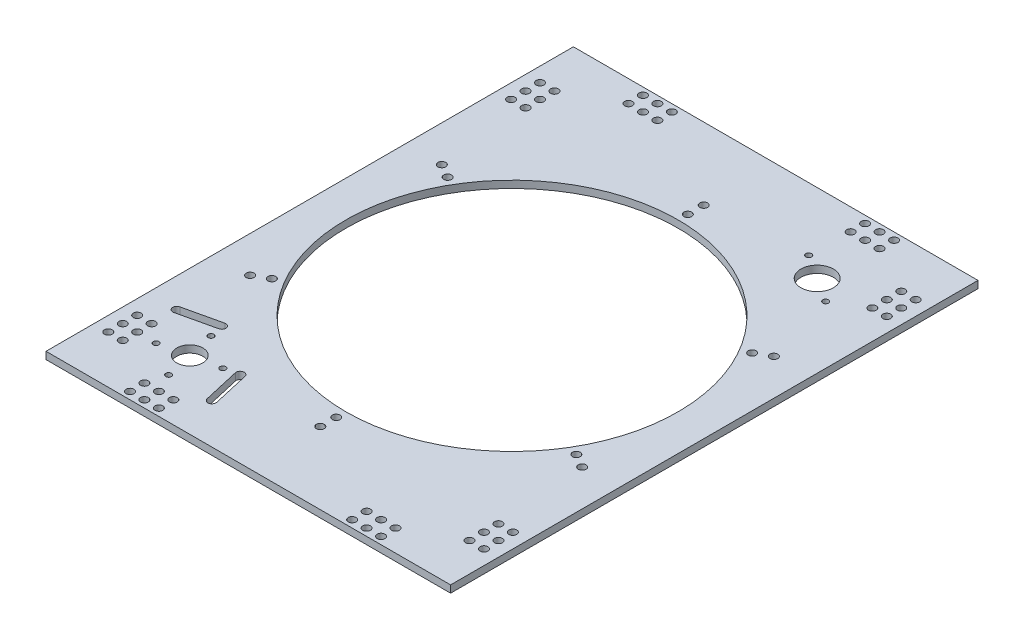
from build123d import *

# Parameters (mm, degrees)
SKETCH1_W           = 355.6
SKETCH1_H           = 463.55
SKETCH1_R           = 146.05
SKETCH1_R_2         = 3.429
SKETCH1_R_3         = 2.54
SKETCH1_R_4         = 11.43
SKETCH1_R_5         = 14.2875
BOSS_EXTRUDE1_DEPTH = 6.35


with BuildPart() as part:
    # Sketch1 → Boss-Extrude1 (new body)
    with BuildSketch(Plane(origin=(0, 0, 0), x_dir=(1, 0, 0), z_dir=(0, 1, 0))):
        Rectangle(SKETCH1_W, SKETCH1_H)
        Circle(SKETCH1_R, mode=Mode.SUBTRACT)
        with Locations((0, 168.5)):
            Circle(SKETCH1_R_2, mode=Mode.SUBTRACT)
        with Locations((145.925280538, 84.25)):
            Circle(SKETCH1_R_2, mode=Mode.SUBTRACT)
        with Locations((145.925280538, -84.25)):
            Circle(SKETCH1_R_2, mode=Mode.SUBTRACT)
        with Locations((0, -168.5)):
            Circle(SKETCH1_R_2, mode=Mode.SUBTRACT)
        with Locations((-145.925280538, -84.25)):
            Circle(SKETCH1_R_2, mode=Mode.SUBTRACT)
        with Locations((-145.925280538, 84.25)):
            Circle(SKETCH1_R_2, mode=Mode.SUBTRACT)
        with Locations((-165.1, 189.7126)):
            Circle(SKETCH1_R_2, mode=Mode.SUBTRACT)
        with Locations((-152.4, 189.7126)):
            Circle(SKETCH1_R_2, mode=Mode.SUBTRACT)
        with Locations((-152.4, 177.0126)):
            Circle(SKETCH1_R_2, mode=Mode.SUBTRACT)
        with Locations((-165.1, 177.0126)):
            Circle(SKETCH1_R_2, mode=Mode.SUBTRACT)
        with Locations((-152.4, 164.3126)):
            Circle(SKETCH1_R_2, mode=Mode.SUBTRACT)
        with Locations((-165.1, 164.3126)):
            Circle(SKETCH1_R_2, mode=Mode.SUBTRACT)
        with Locations((165.1, 164.3126)):
            Circle(SKETCH1_R_2, mode=Mode.SUBTRACT)
        with Locations((152.4, 164.3126)):
            Circle(SKETCH1_R_2, mode=Mode.SUBTRACT)
        with Locations((165.1, 177.0126)):
            Circle(SKETCH1_R_2, mode=Mode.SUBTRACT)
        with Locations((152.4, 177.0126)):
            Circle(SKETCH1_R_2, mode=Mode.SUBTRACT)
        with Locations((152.4, 189.7126)):
            Circle(SKETCH1_R_2, mode=Mode.SUBTRACT)
        with Locations((165.1, 189.7126)):
            Circle(SKETCH1_R_2, mode=Mode.SUBTRACT)
        with Locations((165.1, -189.7126)):
            Circle(SKETCH1_R_2, mode=Mode.SUBTRACT)
        with Locations((152.4, -189.7126)):
            Circle(SKETCH1_R_2, mode=Mode.SUBTRACT)
        with Locations((152.4, -177.0126)):
            Circle(SKETCH1_R_2, mode=Mode.SUBTRACT)
        with Locations((165.1, -177.0126)):
            Circle(SKETCH1_R_2, mode=Mode.SUBTRACT)
        with Locations((152.4, -164.3126)):
            Circle(SKETCH1_R_2, mode=Mode.SUBTRACT)
        with Locations((165.1, -164.3126)):
            Circle(SKETCH1_R_2, mode=Mode.SUBTRACT)
        with Locations((-165.1, -164.3126)):
            Circle(SKETCH1_R_2, mode=Mode.SUBTRACT)
        with Locations((-152.4, -164.3126)):
            Circle(SKETCH1_R_2, mode=Mode.SUBTRACT)
        with Locations((-165.1, -177.0126)):
            Circle(SKETCH1_R_2, mode=Mode.SUBTRACT)
        with Locations((-152.4, -177.0126)):
            Circle(SKETCH1_R_2, mode=Mode.SUBTRACT)
        with Locations((-152.4, -189.7126)):
            Circle(SKETCH1_R_2, mode=Mode.SUBTRACT)
        with Locations((-165.1, -189.7126)):
            Circle(SKETCH1_R_2, mode=Mode.SUBTRACT)
        with Locations((-110.3376, 225.425)):
            Circle(SKETCH1_R_2, mode=Mode.SUBTRACT)
        with Locations((-97.6376, 225.425)):
            Circle(SKETCH1_R_2, mode=Mode.SUBTRACT)
        with Locations((-84.9376, 225.425)):
            Circle(SKETCH1_R_2, mode=Mode.SUBTRACT)
        with Locations((-97.6376, 212.725)):
            Circle(SKETCH1_R_2, mode=Mode.SUBTRACT)
        with Locations((-84.9376, 212.725)):
            Circle(SKETCH1_R_2, mode=Mode.SUBTRACT)
        with Locations((-110.3376, 212.725)):
            Circle(SKETCH1_R_2, mode=Mode.SUBTRACT)
        with Locations((110.3376, 212.725)):
            Circle(SKETCH1_R_2, mode=Mode.SUBTRACT)
        with Locations((84.9376, 212.725)):
            Circle(SKETCH1_R_2, mode=Mode.SUBTRACT)
        with Locations((97.6376, 212.725)):
            Circle(SKETCH1_R_2, mode=Mode.SUBTRACT)
        with Locations((84.9376, 225.425)):
            Circle(SKETCH1_R_2, mode=Mode.SUBTRACT)
        with Locations((97.6376, 225.425)):
            Circle(SKETCH1_R_2, mode=Mode.SUBTRACT)
        with Locations((110.3376, 225.425)):
            Circle(SKETCH1_R_2, mode=Mode.SUBTRACT)
        with Locations((110.3376, -225.425)):
            Circle(SKETCH1_R_2, mode=Mode.SUBTRACT)
        with Locations((97.6376, -225.425)):
            Circle(SKETCH1_R_2, mode=Mode.SUBTRACT)
        with Locations((84.9376, -225.425)):
            Circle(SKETCH1_R_2, mode=Mode.SUBTRACT)
        with Locations((97.6376, -212.725)):
            Circle(SKETCH1_R_2, mode=Mode.SUBTRACT)
        with Locations((84.9376, -212.725)):
            Circle(SKETCH1_R_2, mode=Mode.SUBTRACT)
        with Locations((110.3376, -212.725)):
            Circle(SKETCH1_R_2, mode=Mode.SUBTRACT)
        with Locations((-110.3376, -212.725)):
            Circle(SKETCH1_R_2, mode=Mode.SUBTRACT)
        with Locations((-84.9376, -212.725)):
            Circle(SKETCH1_R_2, mode=Mode.SUBTRACT)
        with Locations((-97.6376, -212.725)):
            Circle(SKETCH1_R_2, mode=Mode.SUBTRACT)
        with Locations((-84.9376, -225.425)):
            Circle(SKETCH1_R_2, mode=Mode.SUBTRACT)
        with Locations((-97.6376, -225.425)):
            Circle(SKETCH1_R_2, mode=Mode.SUBTRACT)
        with Locations((-110.3376, -225.425)):
            Circle(SKETCH1_R_2, mode=Mode.SUBTRACT)
        with Locations((-116.969340251, -147.611717522)):
            Circle(SKETCH1_R_3, mode=Mode.SUBTRACT)
        with Locations((-87.146214855, -166.979081607)):
            Circle(SKETCH1_R_3, mode=Mode.SUBTRACT)
        with Locations((-105.904201711, -195.863848358)):
            Circle(SKETCH1_R_3, mode=Mode.SUBTRACT)
        with Locations((-135.562836399, -177.27035221)):
            Circle(SKETCH1_R_3, mode=Mode.SUBTRACT)
        with Locations((-111.436770981, -171.73778294)):
            Circle(SKETCH1_R_4, mode=Mode.SUBTRACT)
        with Locations((105.605508889, 162.618223125)):
            Circle(SKETCH1_R_5, mode=Mode.SUBTRACT)
        with Locations((84.303276464, 176.452054614)):
            Circle(SKETCH1_R_3, mode=Mode.SUBTRACT)
        with Locations((126.907741315, 148.784391635)):
            Circle(SKETCH1_R_3, mode=Mode.SUBTRACT)
        with Locations((0, 154.5)):
            Circle(SKETCH1_R_2, mode=Mode.SUBTRACT)
        with Locations((133.800924885, 77.25)):
            Circle(SKETCH1_R_2, mode=Mode.SUBTRACT)
        with Locations((133.800924885, -77.25)):
            Circle(SKETCH1_R_2, mode=Mode.SUBTRACT)
        with Locations((0, -154.5)):
            Circle(SKETCH1_R_2, mode=Mode.SUBTRACT)
        with Locations((-133.800924885, -77.25)):
            Circle(SKETCH1_R_2, mode=Mode.SUBTRACT)
        with Locations((-133.800924885, 77.25)):
            Circle(SKETCH1_R_2, mode=Mode.SUBTRACT)
        with BuildLine():
            Line((-71.301492569, -163.345583061), (-63.920948648, -195.530175204))
            ThreePointArc((-63.920948648, -195.530175204), (-66.592153841, -199.791036011), (-70.853014648, -197.119830818))
            Line((-70.853014648, -197.119830818), (-78.233558569, -164.935238675))
            ThreePointArc((-78.233558569, -164.935238675), (-75.562353376, -160.674377868), (-71.301492569, -163.345583061))
        make_face(mode=Mode.SUBTRACT)
        with BuildLine():
            Line((-119.013183183, -138.699061236), (-151.197775326, -146.079605157))
            ThreePointArc((-151.197775326, -146.079605157), (-155.458636133, -143.408399964), (-152.78743094, -139.147539157))
            Line((-152.78743094, -139.147539157), (-120.602838797, -131.766995236))
            ThreePointArc((-120.602838797, -131.766995236), (-116.34197799, -134.438200429), (-119.013183183, -138.699061236))
        make_face(mode=Mode.SUBTRACT)
    extrude(amount=BOSS_EXTRUDE1_DEPTH)


solid = part.part
